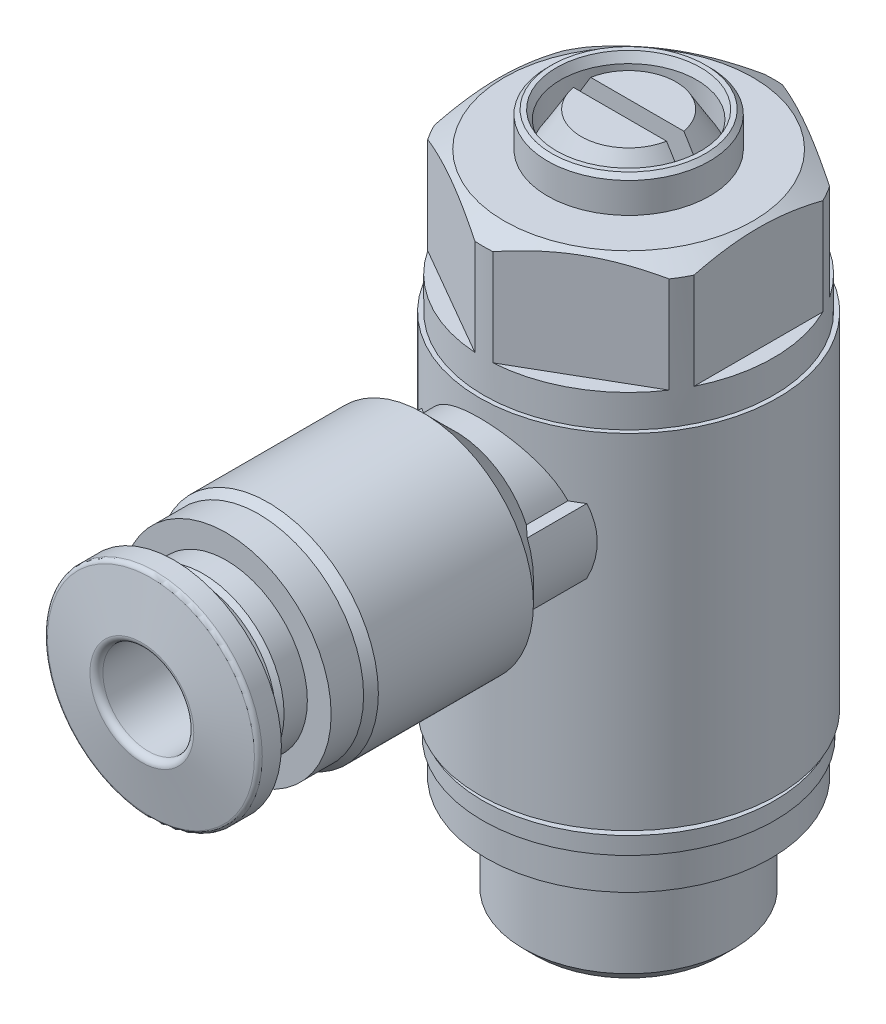
from build123d import *

# Parameters (mm, degrees)
SCHNITT_LINEAR_AUSTRAGEN1_DEPTH      = 1.2
SKIZZE3_W                            = 24
SKIZZE3_H                            = 24
SCHNITT_LINEAR_AUSTRAGEN2_DEPTH      = 6.6
AUFSATZ_LINEAR_AUSTRAGEN1_DEPTH      = 11.25
SCHNITT_LINEAR_AUSTRAGEN3_DEPTH      = 0.4
SCHNITT_LINEAR_AUSTRAGEN3_DEPTH_BACK = 0.4
SKIZZE8_W                            = 5.9
SKIZZE8_H                            = 0.5


with BuildPart() as part:
    # Skizze1 → Rotation1 (revolve)
    with BuildSketch(Plane(origin=(0, 0, 0), x_dir=(0, 0, -1), z_dir=(1, 0, 0))):
        with BuildLine():
            Line((0, 12.5), (2.1915, 12.5))
            Line((2.1915, 12.5), (3.15, 10.9))
            Line((3.15, 10.9), (3.15, 12.1))
            Line((3.15, 12.1), (3.336523063, 12.5))
            Line((3.336523063, 12.5), (3.55, 12.5))
            Line((3.55, 12.5), (3.75, 12.3))
            Line((3.75, 12.3), (3.75, 10.9))
            Line((3.75, 10.9), (5.75, 10.9))
            Line((5.75, 10.9), (6.7, 10.351517244))
            Line((6.7, 10.351517244), (6.7, 4.4))
            Line((6.7, 4.4), (6.9, 4.4))
            Line((6.9, 4.4), (6.9, -11.5))
            Line((6.9, -11.5), (6.075, -11.5))
            ThreePointArc((6.075, -11.5), (6.162867966, -11.712132034), (6.375, -11.8))
            Line((6.375, -11.8), (6.75, -11.8))
            Line((6.75, -11.8), (6.75, -12.6))
            Line((6.75, -12.6), (6.575, -12.6))
            Line((6.575, -12.6), (6.575, -14.2))
            Line((6.575, -14.2), (4.864, -14.2))
            Line((4.864, -14.2), (4.864, -18.669))
            Line((4.864, -18.669), (4.283, -19.25))
            Line((4.283, -19.25), (0, -19.25))
            Line((0, -19.25), (0, 12.5))
        make_face()
    revolve(axis=Axis((0, -19.25, 0), (0, 1, 0)))

    # Skizze2 → Schnitt-Linear austragen1 (cut)
    with BuildSketch(Plane(origin=(0, 12.5, 0), x_dir=(1, 0, 0), z_dir=(0, 1, 0))):
        with BuildLine():
            Line((-3.07408523, -0.4), (3.07408523, -0.4))
            ThreePointArc((3.07408523, -0.4), (3.1, 0), (3.07408523, 0.4))
            Line((3.07408523, 0.4), (-3.07408523, 0.4))
            ThreePointArc((-3.07408523, 0.4), (-3.1, 0), (-3.07408523, -0.4))
        make_face()
    extrude(amount=-SCHNITT_LINEAR_AUSTRAGEN1_DEPTH, mode=Mode.SUBTRACT)

    # Skizze3 → Schnitt-Linear austragen2 (cut)
    with BuildSketch(Plane(origin=(0, 12.5, 0), x_dir=(1, 0, 0), z_dir=(0, 1, 0))):
        Rectangle(SKIZZE3_W, SKIZZE3_H)
        Polygon((-6, -3.464101615), (0, -6.92820323), (6, -3.464101615), (6, 3.464101615), (0, 6.92820323), (-6, 3.464101615), align=None, mode=Mode.SUBTRACT)
    extrude(amount=-SCHNITT_LINEAR_AUSTRAGEN2_DEPTH, mode=Mode.SUBTRACT)

    # Skizze4 → Rotation2 (revolve)
    with BuildSketch(Plane(origin=(0, 0, 0), x_dir=(0, 0, -1), z_dir=(1, 0, 0))):
        with BuildLine():
            Line((-22.5, 0), (-22.5, 2.4))
            Line((-22.5, 2.4), (-22.079507824, 4.784729636))
            ThreePointArc((-22.079507824, 4.784729636), (-22.011103795, 4.903208889), (-21.882546273, 4.95))
            Line((-21.882546273, 4.95), (-21, 4.95))
            Line((-21, 4.95), (-21, 3.1))
            ThreePointArc((-21, 3.1), (-20.882842712, 2.817157288), (-20.6, 2.7))
            Line((-20.6, 2.7), (-19.875, 2.7))
            Line((-19.875, 2.7), (-19.875, 3.55))
            Line((-19.875, 3.55), (-19.675, 3.75))
            Line((-19.675, 3.75), (-18.6, 3.75))
            Line((-18.6, 3.75), (-18.6, 4.85))
            Line((-18.6, 4.85), (-17.1, 4.85))
            Line((-17.1, 4.85), (-16.666987298, 5.1))
            Line((-16.666987298, 5.1), (-9.5, 5.1))
            Line((-9.5, 5.1), (-8, 3.6))
            Line((-8, 3.6), (0, 3.6))
            Line((0, 3.6), (0, 0))
            Line((0, 0), (-22.5, 0))
        make_face()
    revolve(axis=Axis((0, 0, 0), (0, 0, 1)))

    # Skizze5 → Aufsatz-Linear austragen1 (add)
    with BuildSketch(Plane.XY):
        with BuildLine():
            Line((-3.815756806, -1.5), (3.815756806, -1.5))
            ThreePointArc((3.815756806, -1.5), (4.1, 0), (3.815756806, 1.5))
            Line((3.815756806, 1.5), (-3.815756806, 1.5))
            ThreePointArc((-3.815756806, 1.5), (-4.1, 0), (-3.815756806, -1.5))
        make_face()
    extrude(amount=AUFSATZ_LINEAR_AUSTRAGEN1_DEPTH)

    # Skizze6 → Schnitt-Rotation1 (revolve, cut)
    with BuildSketch(Plane(origin=(0, 0, 0), x_dir=(0, 0, -1), z_dir=(1, 0, 0))):
        with BuildLine():
            Line((-22.5, 0), (-22.5, 2.4))
            ThreePointArc((-22.5, 2.4), (-22.412132034, 2.187867966), (-22.2, 2.1))
            Line((-22.2, 2.1), (-7.5, 2.1))
            Line((-7.5, 2.1), (-7.5, 1.5))
            Line((-7.5, 1.5), (0, 1.5))
            Line((0, 1.5), (0, 0))
            Line((0, 0), (-22.5, 0))
        make_face()
    revolve(axis=Axis((0, 0, 0), (0, 0, 1)), mode=Mode.SUBTRACT)

    # Skizze7 → Schnitt-Rotation2 (revolve, cut)
    with BuildSketch(Plane(origin=(0, 0, 0), x_dir=(0, 0, -1), z_dir=(1, 0, 0))):
        with BuildLine():
            Line((1.5, 0.1), (1.5, -19.05))
            Line((1.5, -19.05), (1.615470054, -19.25))
            Line((1.615470054, -19.25), (0, -19.25))
            Line((0, -19.25), (0, 1.6))
            ThreePointArc((0, 1.6), (1.060660172, 1.160660172), (1.5, 0.1))
        make_face()
    revolve(axis=Axis((0, -19.25, 0), (0, 1, 0)), mode=Mode.SUBTRACT)

    # Skizze8 → Schnitt-Linear austragen3 (cut, two sides: drawn at the far end of the back side and taken through both)
    with BuildSketch(Plane.XY.offset(-SCHNITT_LINEAR_AUSTRAGEN3_DEPTH_BACK)):
        with Locations((0, 11.25)):
            Rectangle(SKIZZE8_W, SKIZZE8_H)
    extrude(amount=SCHNITT_LINEAR_AUSTRAGEN3_DEPTH + SCHNITT_LINEAR_AUSTRAGEN3_DEPTH_BACK, mode=Mode.SUBTRACT)


solid = part.part
